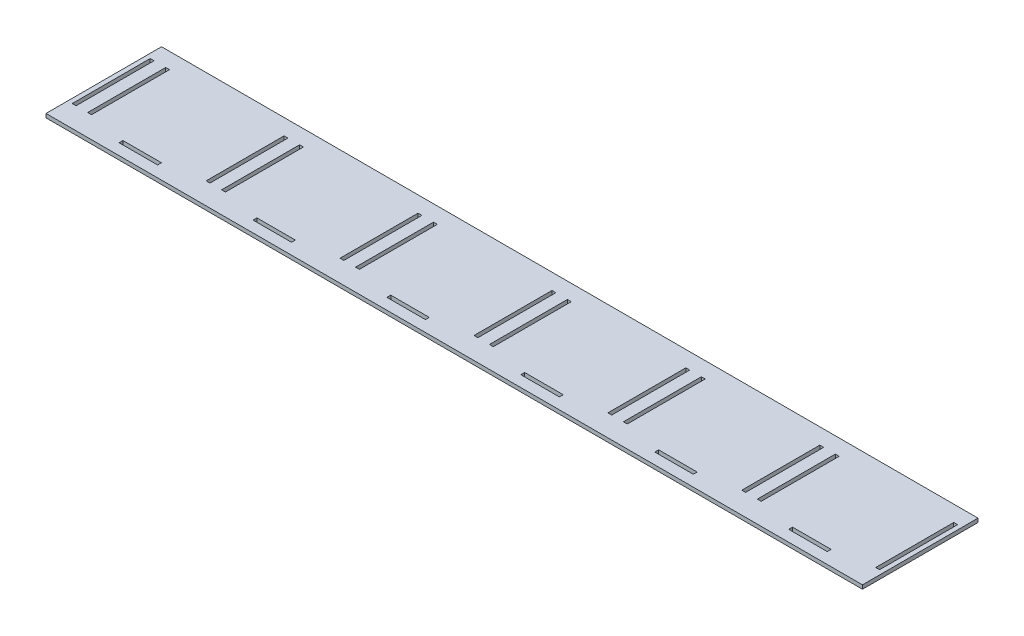
from build123d import *

# Parameters (mm, degrees)
SKETCH1_W           = 424
SKETCH1_H           = 60
SKETCH1_W_2         = 2
SKETCH1_H_2         = 40.5
SKETCH1_W_3         = 20
SKETCH1_H_3         = 2
BOSS_EXTRUDE2_DEPTH = 2


with BuildPart() as part:
    # Sketch1 → Boss-Extrude2 (new body)
    with BuildSketch(Plane(origin=(0, 0, 0), x_dir=(1, 0, 0), z_dir=(0, 1, 0))):
        with Locations((212, -30)):
            Rectangle(SKETCH1_W, SKETCH1_H)
        with Locations((80.95, -28.5)):
            Rectangle(SKETCH1_W_2, SKETCH1_H_2, mode=Mode.SUBTRACT)
        with Locations((150.5, -28.5)):
            Rectangle(SKETCH1_W_2, SKETCH1_H_2, mode=Mode.SUBTRACT)
        with Locations((3.35, -28.5)):
            Rectangle(SKETCH1_W_2, SKETCH1_H_2, mode=Mode.SUBTRACT)
        with Locations((72.9, -28.5)):
            Rectangle(SKETCH1_W_2, SKETCH1_H_2, mode=Mode.SUBTRACT)
        with Locations((11.4, -28.5)):
            Rectangle(SKETCH1_W_2, SKETCH1_H_2, mode=Mode.SUBTRACT)
        with Locations((359.15, -28.5)):
            Rectangle(SKETCH1_W_2, SKETCH1_H_2, mode=Mode.SUBTRACT)
        with Locations((351.1, -28.5)):
            Rectangle(SKETCH1_W_2, SKETCH1_H_2, mode=Mode.SUBTRACT)
        with Locations((289.6, -28.5)):
            Rectangle(SKETCH1_W_2, SKETCH1_H_2, mode=Mode.SUBTRACT)
        with Locations((220.05, -28.5)):
            Rectangle(SKETCH1_W_2, SKETCH1_H_2, mode=Mode.SUBTRACT)
        with Locations((142.45, -28.5)):
            Rectangle(SKETCH1_W_2, SKETCH1_H_2, mode=Mode.SUBTRACT)
        with Locations((111.7, -53.2)):
            Rectangle(SKETCH1_W_3, SKETCH1_H_3, mode=Mode.SUBTRACT)
        with Locations((42.15, -53.2)):
            Rectangle(SKETCH1_W_3, SKETCH1_H_3, mode=Mode.SUBTRACT)
        with Locations((212, -28.5)):
            Rectangle(SKETCH1_W_2, SKETCH1_H_2, mode=Mode.SUBTRACT)
        with Locations((281.55, -28.5)):
            Rectangle(SKETCH1_W_2, SKETCH1_H_2, mode=Mode.SUBTRACT)
        with Locations((181.25, -53.2)):
            Rectangle(SKETCH1_W_3, SKETCH1_H_3, mode=Mode.SUBTRACT)
        with Locations((250.8, -53.2)):
            Rectangle(SKETCH1_W_3, SKETCH1_H_3, mode=Mode.SUBTRACT)
        with Locations((420.65, -28.5)):
            Rectangle(SKETCH1_W_2, SKETCH1_H_2, mode=Mode.SUBTRACT)
        with Locations((320.35, -53.2)):
            Rectangle(SKETCH1_W_3, SKETCH1_H_3, mode=Mode.SUBTRACT)
        with Locations((389.9, -53.2)):
            Rectangle(SKETCH1_W_3, SKETCH1_H_3, mode=Mode.SUBTRACT)
    extrude(amount=BOSS_EXTRUDE2_DEPTH)


solid = part.part
